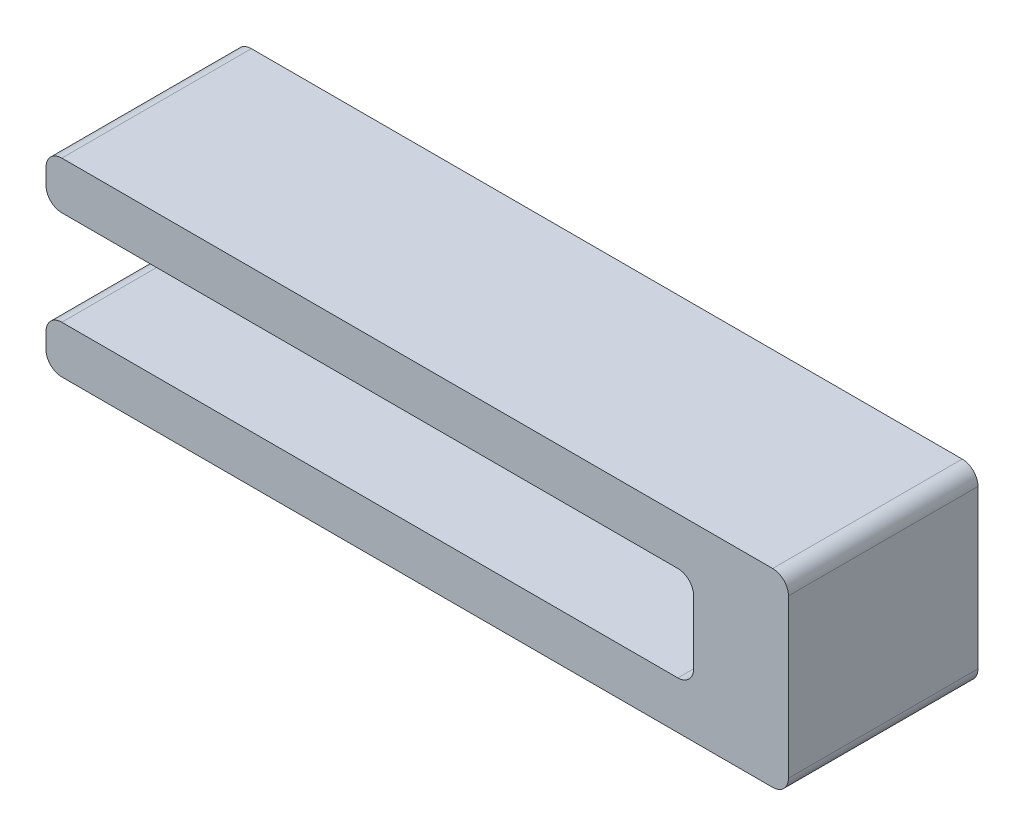
from build123d import *

# Parameters (mm, degrees)
BOSS_EXTRUDE1_DEPTH = 6
FILLET1_R           = 0.5


with BuildPart() as part:
    # Sketch2 → Boss-Extrude1 (new body)
    with BuildSketch(Plane.XY):
        Polygon((0, 1.5), (0, 0), (23.5, 0), (23.5, 6), (0, 6), (0, 4.5), (20.5, 4.5), (20.5, 1.5), align=None)
    extrude(amount=BOSS_EXTRUDE1_DEPTH)

    # Fillet1
    fillet1_edges = [part.edges().sort_by_distance(p)[0] for p in [
        (0, 4.5, 3),
        (0, 6, 3),
        (23.5, 6, 3),
        (23.5, 0, 3),
        (0, 0, 3),
        (0, 1.5, 3),
        (20.5, 1.5, 3),
        (20.5, 4.5, 3),
    ]]
    fillet(fillet1_edges, radius=FILLET1_R)


solid = part.part
